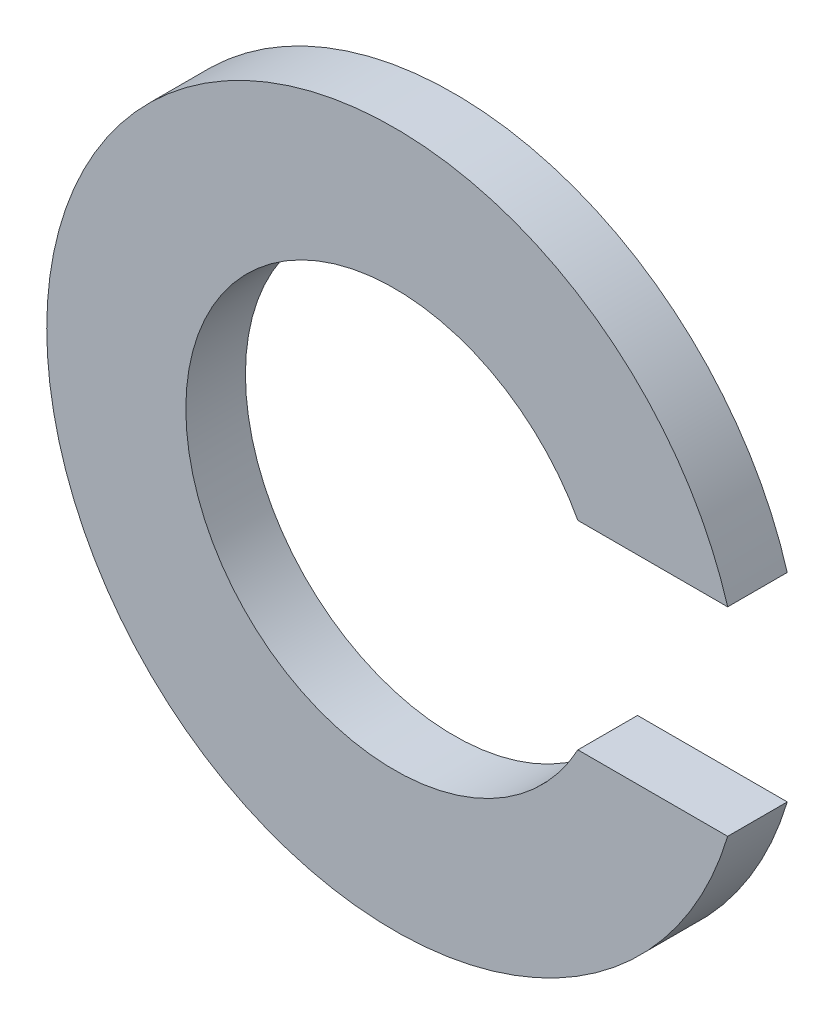
from build123d import *

# Parameters (mm, degrees)
BOSS_EXTRUDE1_DEPTH = 0.6


with BuildPart() as part:
    # Sketch1 → Boss-Extrude1 (new body)
    with BuildSketch(Plane.XY):
        with BuildLine():
            Line((1.846618531, 1), (3.354101966, 1))
            ThreePointArc((3.354101966, 1), (-3.5, 0), (3.354101966, -1))
            Line((3.354101966, -1), (1.846618531, -1))
            ThreePointArc((1.846618531, -1), (-2.1, 0), (1.846618531, 1))
        make_face()
    extrude(amount=BOSS_EXTRUDE1_DEPTH)


solid = part.part
